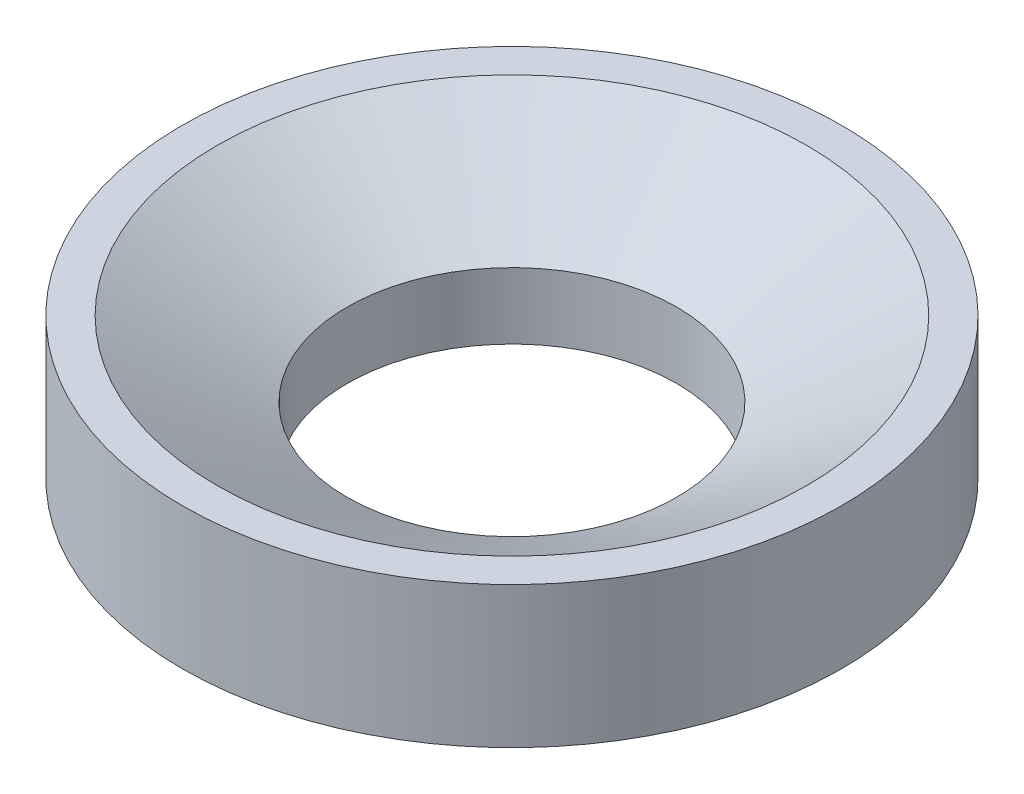
from build123d import *


with BuildPart() as part:
    # Sketch2 → Revolve1 (revolve)
    with BuildSketch(Plane.XY):
        Polygon((79.507616708, 38.1), (88.9, 38.1), (88.9, 0), (44.45, 0), (44.45, 17.859475557), align=None)
    revolve(axis=Axis((0, 44.668427518, 0), (0, -1, 0)))


solid = part.part
